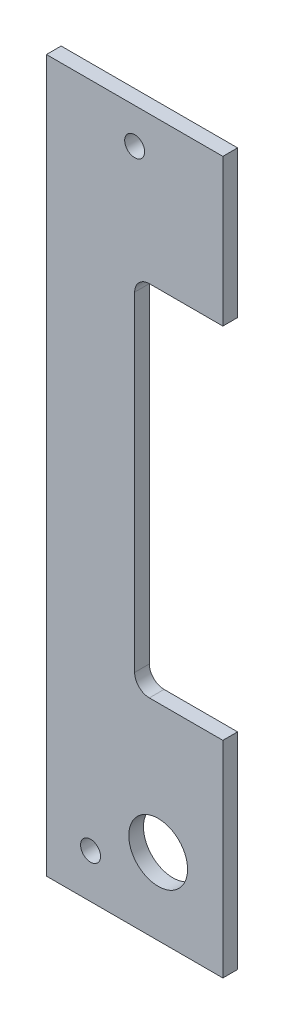
from build123d import *

# Parameters (mm, degrees)
BOSS_EXTRUDE1_DEPTH        = 3.175
F_6_CLEARANCE_HOLE1_D      = 4.3053
F_1_2_0_5_DIAMETER_HOLE1_D = 12.7


with BuildPart() as part:
    # Sketch1 → Boss-Extrude1 (new body)
    with BuildSketch(Plane.XY):
        with BuildLine():
            Line((0, 0), (0, 44.45))
            Line((0, 44.45), (-15.875, 44.45))
            ThreePointArc((-15.875, 44.45), (-18.12006403, 45.37993597), (-19.05, 47.625))
            Line((-19.05, 47.625), (-19.05, 118.745))
            ThreePointArc((-19.05, 118.745), (-18.12006403, 120.99006403), (-15.875, 121.92))
            Line((-15.875, 121.92), (0, 121.92))
            Line((0, 121.92), (0, 153.67))
            Line((0, 153.67), (-38.1, 153.67))
            Line((-38.1, 153.67), (-38.1, 0))
            Line((-38.1, 0), (0, 0))
        make_face()
    extrude(amount=BOSS_EXTRUDE1_DEPTH)

    # #6 Clearance Hole1 (through all)
    with Locations(Plane(origin=(0, 0, 0), x_dir=(-1, 0, 0), z_dir=(0, 0, -1))):
        with Locations((28.575, 9.525), (19.05, 146.05)):
            Hole(F_6_CLEARANCE_HOLE1_D / 2)

    # 1/2 (0.5) Diameter Hole1 (through all)
    with Locations(Plane(origin=(0, 0, 0), x_dir=(-1, 0, 0), z_dir=(0, 0, -1))):
        with Locations((13.97, 16.51)):
            Hole(F_1_2_0_5_DIAMETER_HOLE1_D / 2)


solid = part.part
